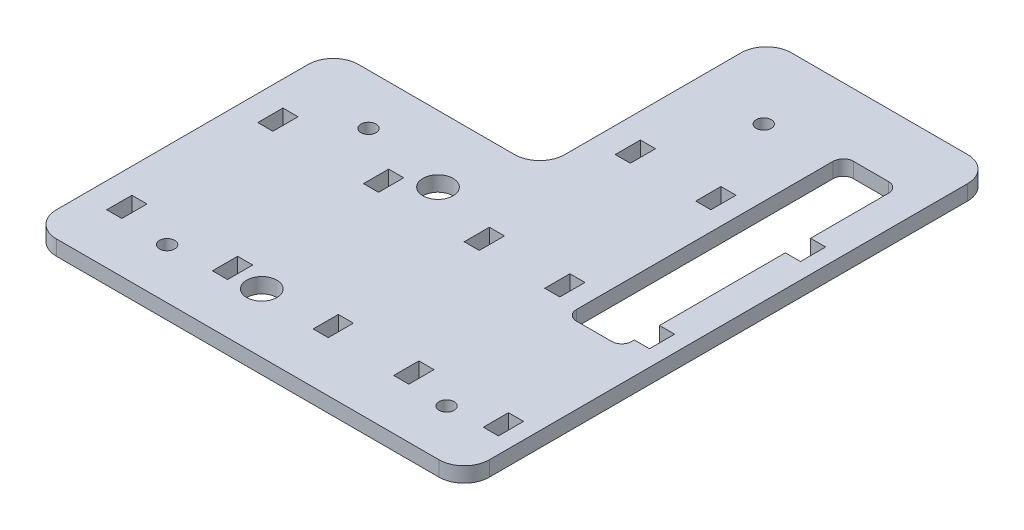
from build123d import *

# Parameters (mm, degrees)
SKETCH1_W           = 86
SKETCH1_H           = 105
BOSS_EXTRUDE1_DEPTH = 3
SKETCH2_W           = 3
SKETCH2_H           = 5
CUT_EXTRUDE1_DEPTH  = 3
LPATTERN1_COUNT     = 3
LPATTERN1_PITCH     = 30
SKETCH5_R           = 1.5
CUT_EXTRUDE2_DEPTH  = 4
SKETCH6_R           = 3
SKETCH6_W           = 11
SKETCH6_H           = 55
CUT_EXTRUDE3_DEPTH  = 4
FILLET2_R           = 2
SKETCH7_W           = 41
SKETCH7_H           = 45
CUT_EXTRUDE4_DEPTH  = 4
FILLET3_R           = 5


with BuildPart() as part:
    # Sketch1 → Boss-Extrude1 (new body)
    with BuildSketch(Plane(origin=(0, 0, 0), x_dir=(1, 0, 0), z_dir=(0, 1, 0))):
        with Locations((43, 52.5)):
            Rectangle(SKETCH1_W, SKETCH1_H)
    extrude(amount=BOSS_EXTRUDE1_DEPTH)

    # Sketch2 → Cut-Extrude1 (cut)
    with BuildSketch(Plane(origin=(0, 3, 0), x_dir=(1, 0, 0), z_dir=(0, 1, 0))):
        with Locations((63.5, 12.5)):
            Rectangle(SKETCH2_W, SKETCH2_H)
        with Locations((47.5, 12.5)):
            Rectangle(SKETCH2_W, SKETCH2_H)
        with Locations((27.5, 12.5)):
            Rectangle(SKETCH2_W, SKETCH2_H)
        with Locations((6.5, 12.5)):
            Rectangle(SKETCH2_W, SKETCH2_H)
        with Locations((81.3, 12.5)):
            Rectangle(SKETCH2_W, SKETCH2_H)
    cut_extrude1 = extrude(amount=-CUT_EXTRUDE1_DEPTH, mode=Mode.SUBTRACT)

    # LPattern1: Cut-Extrude1 ×3
    with Locations(*[(0, 0, -i * LPATTERN1_PITCH) for i in range(1, LPATTERN1_COUNT)]):
        add(cut_extrude1, mode=Mode.SUBTRACT)

    # Sketch5 → Cut-Extrude2 (cut, through all)
    with BuildSketch(Plane(origin=(0, 3, 0), x_dir=(1, 0, 0), z_dir=(0, 1, 0))):
        with Locations((17, 10)):
            Circle(SKETCH5_R)
        with Locations((17, 50)):
            Circle(SKETCH5_R)
        with Locations((72.5, 10)):
            Circle(SKETCH5_R)
        with Locations((55.5, 90)):
            Circle(SKETCH5_R)
    extrude(amount=-CUT_EXTRUDE2_DEPTH, mode=Mode.SUBTRACT)

    # Sketch6 → Cut-Extrude3 (cut, through all)
    with BuildSketch(Plane(origin=(0, 3, 0), x_dir=(1, 0, 0), z_dir=(0, 1, 0))):
        with Locations((34, 11.8)):
            Circle(SKETCH6_R)
        with Locations((34, 46.8)):
            Circle(SKETCH6_R)
        with Locations((74.3, 65)):
            Rectangle(SKETCH6_W, SKETCH6_H)
    extrude(amount=-CUT_EXTRUDE3_DEPTH, mode=Mode.SUBTRACT)

    # Fillet2
    fillet2_edges = [part.edges().sort_by_distance(p)[0] for p in [
        (79.8, 1.5, -92.5),
        (68.8, 1.5, -37.5),
        (68.8, 1.5, -92.5),
        (79.8, 1.5, -37.5),
    ]]
    fillet(fillet2_edges, radius=FILLET2_R)

    # Sketch7 → Cut-Extrude4 (cut, through all)
    with BuildSketch(Plane(origin=(0, 3, 0), x_dir=(1, 0, 0), z_dir=(0, 1, 0))):
        with Locations((20.5, 82.5)):
            Rectangle(SKETCH7_W, SKETCH7_H)
    extrude(amount=-CUT_EXTRUDE4_DEPTH, mode=Mode.SUBTRACT)

    # Fillet3
    fillet3_edges = [part.edges().sort_by_distance(p)[0] for p in [
        (0, 1.5, -60),
        (41, 1.5, -105),
        (41, 1.5, -60),
        (86, 1.5, -105),
        (86, 1.5, 0),
        (0, 1.5, 0),
    ]]
    fillet(fillet3_edges, radius=FILLET3_R)


solid = part.part
